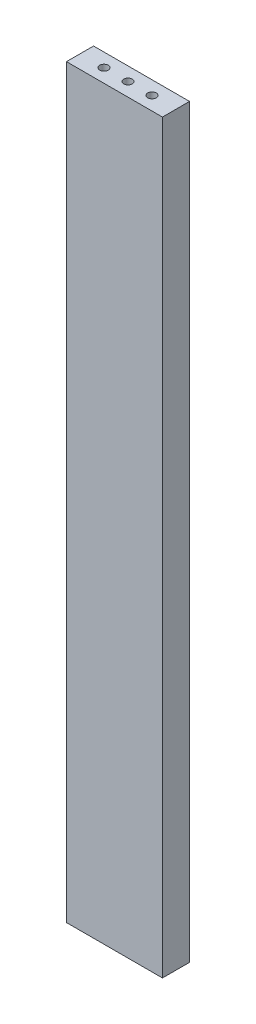
from build123d import *

# Parameters (mm, degrees)
CROQUIS1_W              = 90
CROQUIS1_H              = 25.4
SALIENTE_EXTRUIR1_DEPTH = 699.2
CROQUIS3_R              = 4
CORTAR_EXTRUIR1_DEPTH   = 10
CROQUIS4_R              = 4
CORTAR_EXTRUIR2_DEPTH   = 10


with BuildPart() as part:
    # Croquis1 → Saliente-Extruir1 (new body)
    with BuildSketch(Plane(origin=(0, 0, 0), x_dir=(1, 0, 0), z_dir=(0, 1, 0))):
        Rectangle(CROQUIS1_W, CROQUIS1_H)
    extrude(amount=SALIENTE_EXTRUIR1_DEPTH)

    # Croquis3 → Cortar-Extruir1 (cut)
    with BuildSketch(Plane(origin=(0, 699.2, 0), x_dir=(1, 0, 0), z_dir=(0, 1, 0))):
        Circle(CROQUIS3_R)
        with Locations((22.5, 0)):
            Circle(CROQUIS3_R)
        with Locations((-22.5, 0)):
            Circle(CROQUIS3_R)
    extrude(amount=-CORTAR_EXTRUIR1_DEPTH, mode=Mode.SUBTRACT)

    # Croquis4 → Cortar-Extruir2 (cut)
    with BuildSketch(Plane.XZ):
        Circle(CROQUIS4_R)
        with Locations((22.5, 0)):
            Circle(CROQUIS4_R)
        with Locations((-22.5, 0)):
            Circle(CROQUIS4_R)
    extrude(amount=-CORTAR_EXTRUIR2_DEPTH, mode=Mode.SUBTRACT)


solid = part.part
